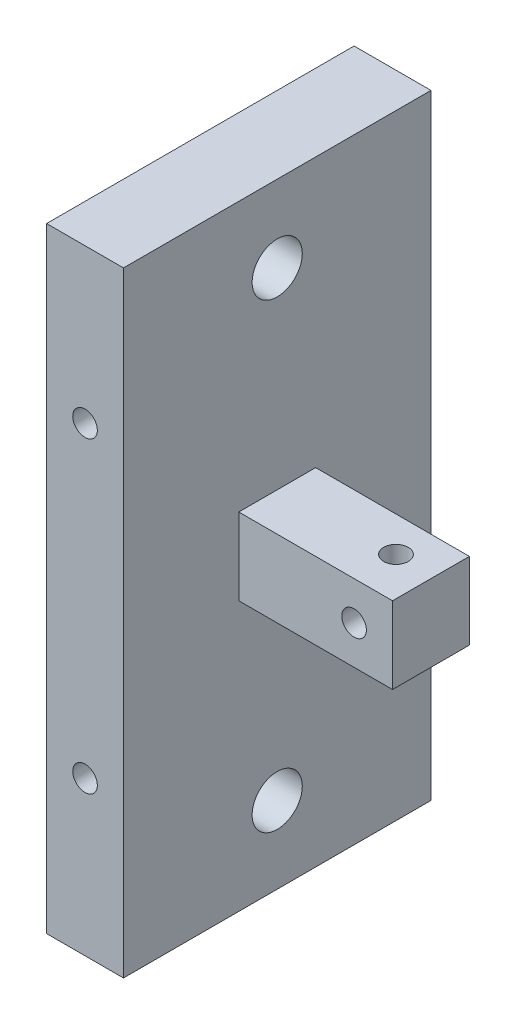
from build123d import *

# Parameters (mm, degrees)
SKETCH1_W                      = 40
SKETCH1_H                      = 80
BOSS_EXTRUDE1_DEPTH            = 10
SKETCH2_W                      = 10
SKETCH2_H                      = 10
BOSS_EXTRUDE2_DEPTH            = 20
F_1_4_CLEARANCE_HOLE1_D        = 6.5278
F_1_4_CLEARANCE_HOLE1_DEPTH    = 21
F_1_4_CLEARANCE_HOLE1_TIP      = 1.961148974
M3_CLEARANCE_HOLE3_D           = 3.2
M3_CLEARANCE_HOLE4_D           = 3.2
M3_CLEARANCE_HOLE4_ON_FACE_2_D = 3.2


with BuildPart() as part:
    # Sketch1 → Boss-Extrude1 (new body)
    with BuildSketch(Plane(origin=(0, 0, 0), x_dir=(0, 0, -1), z_dir=(1, 0, 0))):
        with Locations((-1086.086956522, 721.739130435)):
            Rectangle(SKETCH1_W, SKETCH1_H)
    extrude(amount=BOSS_EXTRUDE1_DEPTH)

    # Sketch2 → Boss-Extrude2 (add)
    with BuildSketch(Plane(origin=(10, 0, 0), x_dir=(0, 0, -1), z_dir=(1, 0, 0))):
        with Locations((-1086.086956522, 721.739130435)):
            Rectangle(SKETCH2_W, SKETCH2_H)
    extrude(amount=BOSS_EXTRUDE2_DEPTH)

    # 1/4 Clearance Hole1
    with Locations(Plane(origin=(10, 751.739130435, 1086.086956522), x_dir=(0, 0, 1), z_dir=(1, 0, 0))):
        with Locations((0, 0), (0, 60)):
            Hole(F_1_4_CLEARANCE_HOLE1_D / 2, depth=F_1_4_CLEARANCE_HOLE1_DEPTH)
            with Locations((0, 0, -(F_1_4_CLEARANCE_HOLE1_DEPTH + F_1_4_CLEARANCE_HOLE1_TIP / 2))):  # 118° drill point
                Cone(0, F_1_4_CLEARANCE_HOLE1_D / 2, F_1_4_CLEARANCE_HOLE1_TIP, mode=Mode.SUBTRACT)

    # M3 Clearance Hole3 (through all)
    with Locations(Plane(origin=(5, 701.739130435, 1066.086956522), x_dir=(-1, 0, 0), z_dir=(0, 0, -1))):
        with Locations((0, 0), (0, 40)):
            Hole(M3_CLEARANCE_HOLE3_D / 2)

    # M3 Clearance Hole4 (through all)
    with Locations(Plane(origin=(25, 726.739130435, 1085.639739232), x_dir=(0, 0, 1), z_dir=(0, 1, 0))):
        with Locations((0, 0)):
            Hole(M3_CLEARANCE_HOLE4_D / 2)

    # M3 Clearance Hole4 on face 2 (through all)
    with Locations(Plane(origin=(25, 721.739130435, 1081.086956522), x_dir=(-1, 0, 0), z_dir=(0, 0, -1))):
        with Locations((0, 0)):
            Hole(M3_CLEARANCE_HOLE4_ON_FACE_2_D / 2)


solid = part.part
